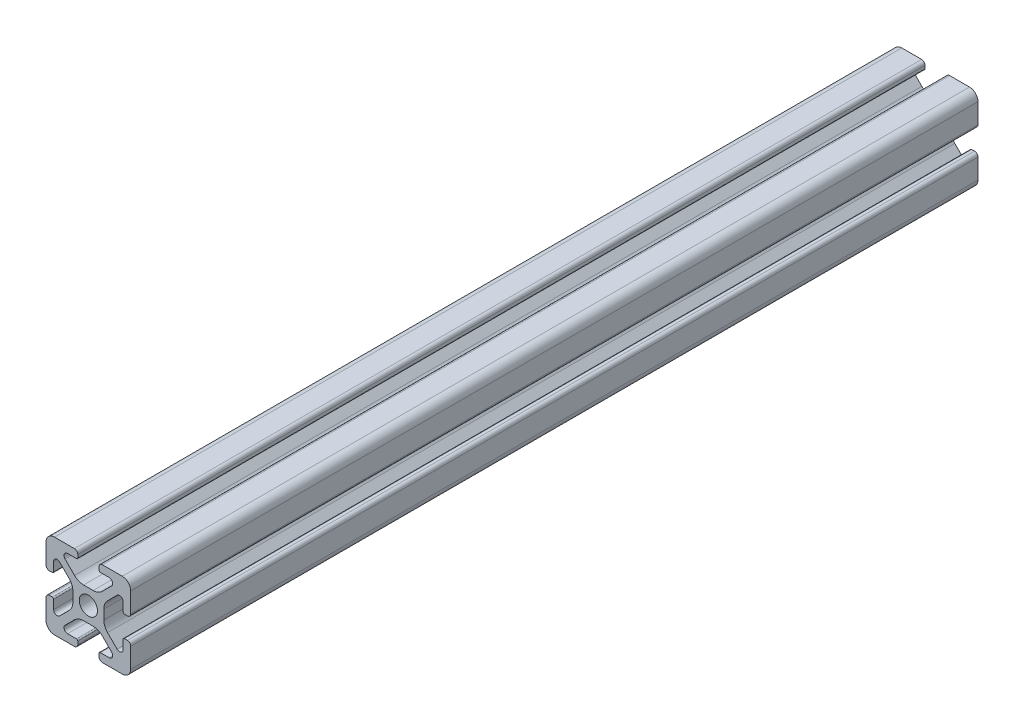
from build123d import *

# Parameters (mm, degrees)
SKETCH1_R           = 2.15
BOSS_EXTRUDE1_DEPTH = 200


with BuildPart() as part:
    # Sketch1 → Boss-Extrude1 (new body)
    with BuildSketch(Plane(origin=(0, 0, 0), x_dir=(-1, 0, 0), z_dir=(0, 0, -1))):
        with BuildLine():
            Line((-12.499999997, 0.800000003), (-12.499999998, 1.500000003))
            ThreePointArc((-12.499999998, 1.500000003), (-12.587867964, 1.712132039), (-12.8, 1.800000005))
            Line((-12.8, 1.800000005), (-14.9175884, 1.800000005))
            ThreePointArc((-14.9175884, 1.800000005), (-15.686636445, 2.313861481), (-15.506192291, 3.221015502))
            Line((-15.506192291, 3.221015502), (-13.255887451, 5.471320342))
            ThreePointArc((-13.255887451, 5.471320342), (-12.282617405, 6.121638595), (-11.134567109, 6.349999998))
            Line((-11.134567109, 6.349999998), (-8.865432906, 6.349999998))
            ThreePointArc((-8.865432906, 6.349999998), (-7.717382611, 6.121638596), (-6.744112565, 5.471320342))
            Line((-6.744112565, 5.471320342), (-4.493807727, 3.221015504))
            ThreePointArc((-4.493807727, 3.221015504), (-4.313363573, 2.313861481), (-5.082411619, 1.800000005))
            Line((-5.082411619, 1.800000005), (-7.20000001, 1.800000005))
            ThreePointArc((-7.20000001, 1.800000005), (-7.412132045, 1.71213204), (-7.50000001, 1.500000005))
            Line((-7.50000001, 1.500000005), (-7.50000001, 0.8))
            ThreePointArc((-7.50000001, 0.8), (-7.265685435, 0.234314575), (-6.70000001, 0))
            Line((-6.70000001, 0), (-2, 0))
            ThreePointArc((-2, 0), (-0.585786438, 0.585786438), (0, 2))
            Line((0, 2), (0, 6.699999998))
            ThreePointArc((0, 6.699999998), (-0.234314576, 7.265685424), (-0.800000003, 7.5))
            Line((-0.800000003, 7.5), (-1.500000007, 7.5))
            ThreePointArc((-1.500000007, 7.5), (-1.712132044, 7.412132033), (-1.80000001, 7.199999997))
            Line((-1.80000001, 7.199999997), (-1.80000001, 5.082411604))
            ThreePointArc((-1.80000001, 5.082411604), (-2.313861485, 4.313363559), (-3.221015507, 4.493807713))
            Line((-3.221015507, 4.493807713), (-5.471320347, 6.744112553))
            ThreePointArc((-5.471320347, 6.744112553), (-6.1216386, 7.717382599), (-6.350000003, 8.865432896))
            Line((-6.350000003, 8.865432896), (-6.350000003, 11.134567105))
            ThreePointArc((-6.350000003, 11.134567105), (-6.121638601, 12.2826174), (-5.471320347, 13.255887446))
            Line((-5.471320347, 13.255887446), (-3.221015511, 15.506192282))
            ThreePointArc((-3.221015511, 15.506192282), (-2.313861487, 15.686636436), (-1.80000001, 14.917588389))
            Line((-1.80000001, 14.917588389), (-1.80000001, 12.799999998))
            ThreePointArc((-1.80000001, 12.799999998), (-1.712132045, 12.587867963), (-1.50000001, 12.499999997))
            Line((-1.50000001, 12.499999997), (-0.8, 12.499999997))
            ThreePointArc((-0.8, 12.499999997), (-0.234314575, 12.734314573), (0, 13.299999998))
            Line((0, 13.299999998), (0, 18))
            ThreePointArc((0, 18), (-0.585786438, 19.414213562), (-2, 20))
            Line((-2, 20), (-6.700000008, 20))
            ThreePointArc((-6.700000008, 20), (-7.265685435, 19.765685424), (-7.50000001, 19.199999998))
            Line((-7.50000001, 19.199999998), (-7.50000001, 18.500000005))
            ThreePointArc((-7.50000001, 18.500000005), (-7.412132044, 18.287867969), (-7.200000008, 18.200000003))
            Line((-7.200000008, 18.200000003), (-5.082411595, 18.200000003))
            ThreePointArc((-5.082411595, 18.200000003), (-4.313363547, 17.686138525), (-4.493807702, 16.7789845))
            Line((-4.493807702, 16.7789845), (-6.744112543, 14.528679659))
            ThreePointArc((-6.744112543, 14.528679659), (-7.717382589, 13.878361405), (-8.865432885, 13.650000003))
            Line((-8.865432885, 13.650000003), (-11.134567111, 13.650000003))
            ThreePointArc((-11.134567111, 13.650000003), (-12.282617406, 13.878361405), (-13.255887452, 14.528679658))
            Line((-13.255887452, 14.528679658), (-15.506192292, 16.778984498))
            ThreePointArc((-15.506192292, 16.778984498), (-15.686636447, 17.686138525), (-14.917588397, 18.200000002))
            Line((-14.917588397, 18.200000002), (-12.799999998, 18.200000003))
            ThreePointArc((-12.799999998, 18.200000003), (-12.587867963, 18.287867968), (-12.499999997, 18.500000002))
            Line((-12.499999997, 18.500000002), (-12.499999997, 19.2))
            ThreePointArc((-12.499999997, 19.2), (-12.734314573, 19.765685425), (-13.299999998, 20))
            Line((-13.299999998, 20), (-18, 20))
            ThreePointArc((-18, 20), (-19.414213562, 19.414213562), (-20, 18))
            Line((-20, 18), (-20, 13.3))
            ThreePointArc((-20, 13.3), (-19.765685424, 12.734314573), (-19.199999998, 12.499999997))
            Line((-19.199999998, 12.499999997), (-18.500000003, 12.499999997))
            ThreePointArc((-18.500000003, 12.499999997), (-18.287867967, 12.587867964), (-18.2, 12.8))
            Line((-18.2, 12.8), (-18.2, 14.91758839))
            ThreePointArc((-18.2, 14.91758839), (-17.686138525, 15.686636435), (-16.778984504, 15.506192281))
            Line((-16.778984504, 15.506192281), (-14.528679657, 13.255887434))
            ThreePointArc((-14.528679657, 13.255887434), (-13.878361403, 12.282617388), (-13.65, 11.134567091))
            Line((-13.65, 11.134567091), (-13.65, 8.865432887))
            ThreePointArc((-13.65, 8.865432887), (-13.878361403, 7.717382591), (-14.528679656, 6.744112546))
            Line((-14.528679656, 6.744112546), (-16.778984496, 4.493807706))
            ThreePointArc((-16.778984496, 4.493807706), (-17.686138522, 4.313363551), (-18.2, 5.0824116))
            Line((-18.2, 5.0824116), (-18.2, 7.2))
            ThreePointArc((-18.2, 7.2), (-18.287867966, 7.412132034), (-18.5, 7.5))
            Line((-18.5, 7.5), (-19.2, 7.5))
            ThreePointArc((-19.2, 7.5), (-19.765685425, 7.265685425), (-20, 6.7))
            Line((-20, 6.7), (-20, 2))
            ThreePointArc((-20, 2), (-19.414213562, 0.585786438), (-18, 0))
            Line((-18, 0), (-13.3, 0))
            ThreePointArc((-13.3, 0), (-12.734314573, 0.234314576), (-12.499999997, 0.800000003))
        make_face()
        with Locations((-10, 10)):
            Circle(SKETCH1_R, mode=Mode.SUBTRACT)
    extrude(amount=-BOSS_EXTRUDE1_DEPTH)


solid = part.part
